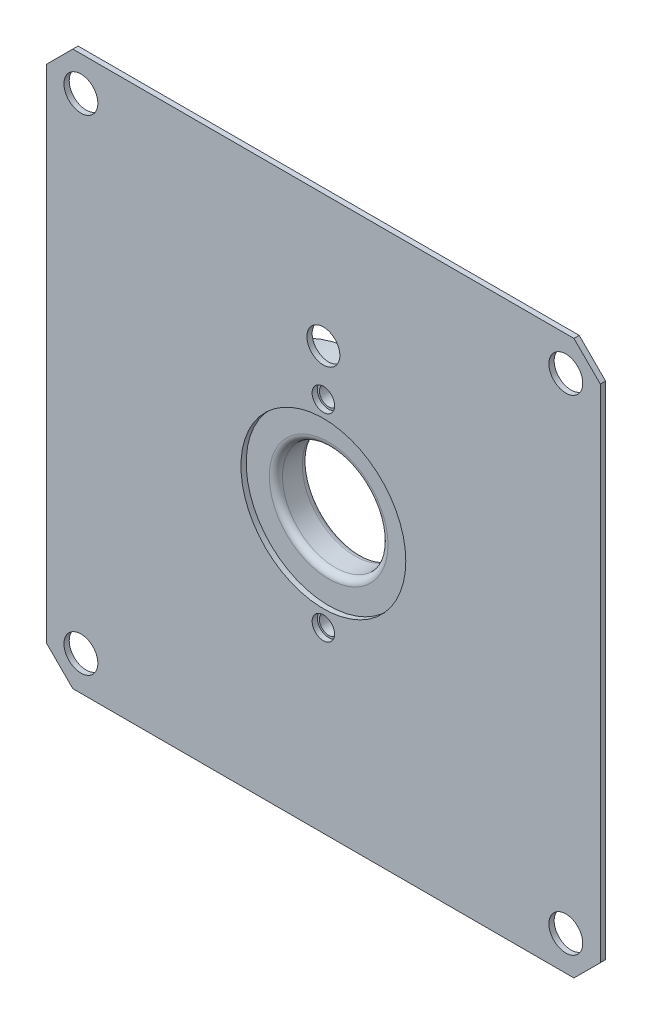
from build123d import *

# Parameters (mm, degrees)
SKETCH1_R             = 11.43
SKETCH1_R_2           = 5.08
BOSS_EXTRUDE1_DEPTH   = 3.175
FILLET1_R             = 0.635
F_2_56_TAPPED_HOLE1_D = 1.778
SKETCH4_W             = 53.34
SKETCH4_H             = 53.34
SKETCH4_R             = 7.9375
SKETCH4_R_2           = 1.084817848
SKETCH4_R_3           = 1.08040081
BOSS_EXTRUDE2_DEPTH   = 0.508
F_4_CLEARANCE_HOLE1_D = 3.2639
CIRPATTERN1_COUNT     = 4
SKETCH9_R             = 1.5875
CUT_EXTRUDE1_DEPTH    = 0.508
CHAMFER1_SIZE         = 2.54


with BuildPart() as part:
    # Sketch1 → Boss-Extrude1 (new body)
    with BuildSketch(Plane.XY):
        Circle(SKETCH1_R)
        Circle(SKETCH1_R_2, mode=Mode.SUBTRACT)
    extrude(amount=BOSS_EXTRUDE1_DEPTH)

    # Fillet1
    fillet1_edges = [part.edges().sort_by_distance(p)[0] for p in [
        (-5.08, 0, 0),
        (-5.08, 0, 3.175),
    ]]
    fillet(fillet1_edges, radius=FILLET1_R)

    # #2-56 Tapped Hole1 (through all)
    with Locations(Plane.XY.offset(3.175)):
        with Locations((0, 9.525)):
            f_2_56_tapped_hole1 = Hole(F_2_56_TAPPED_HOLE1_D / 2)

    # Mirror1: #2-56 Tapped Hole1 across plane
    add(f_2_56_tapped_hole1.mirror(Plane.ZX), mode=Mode.SUBTRACT)

    # Sketch4 → Boss-Extrude2 (add)
    with BuildSketch(Plane.XY.offset(3.175)):
        Rectangle(SKETCH4_W, SKETCH4_H)
        Circle(SKETCH4_R, mode=Mode.SUBTRACT)
        with Locations((0, 9.525)):
            Circle(SKETCH4_R_2, mode=Mode.SUBTRACT)
        with Locations((0, -9.525)):
            Circle(SKETCH4_R_3, mode=Mode.SUBTRACT)
    extrude(amount=BOSS_EXTRUDE2_DEPTH)

    # #4 Clearance Hole1 (through all)
    with Locations(Plane(origin=(0, 0, 3.175), x_dir=(-1, 0, 0), z_dir=(0, 0, -1))):
        with Locations((-23.348665915, -23.348665915)):
            f_4_clearance_hole1 = Hole(F_4_CLEARANCE_HOLE1_D / 2)

    # CirPattern1: #4 Clearance Hole1 ×4 about axis
    cirpattern1_axis = Axis((0, 0, 0), (0, 0, 1))
    for i in range(1, CIRPATTERN1_COUNT):
        add(f_4_clearance_hole1.rotate(cirpattern1_axis, i * 360 / CIRPATTERN1_COUNT), mode=Mode.SUBTRACT)

    # Sketch9 → Cut-Extrude1 (cut)
    with BuildSketch(Plane.XY.offset(3.683)):
        with Locations((0, 13.97)):
            Circle(SKETCH9_R)
    extrude(amount=-CUT_EXTRUDE1_DEPTH, mode=Mode.SUBTRACT)

    # Chamfer1
    chamfer1_edges = [part.edges().sort_by_distance(p)[0] for p in [
        (-26.67, 26.67, 3.429),
        (-26.67, -26.67, 3.429),
        (26.67, -26.67, 3.429),
        (26.67, 26.67, 3.429),
    ]]
    chamfer(chamfer1_edges, length=CHAMFER1_SIZE)


solid = part.part
